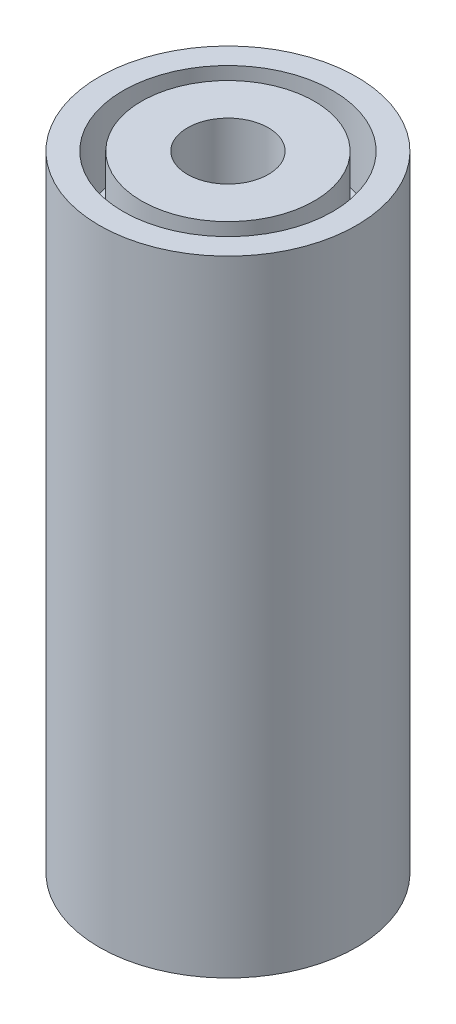
from build123d import *

# Parameters (mm, degrees)
ESQUISSE1_R             = 3.5
ESQUISSE1_R_2           = 1.1
BOSS_EXTRU_2_DEPTH      = 17
ESQUISSE2_R             = 2.85
ESQUISSE2_R_2           = 2.35
ENL_V_MAT_EXTRU_1_DEPTH = 2


with BuildPart() as part:
    # Esquisse1 → Boss.-Extru.2 (new body)
    with BuildSketch(Plane(origin=(0, 0, 0), x_dir=(1, 0, 0), z_dir=(0, 1, 0))):
        Circle(ESQUISSE1_R)
        Circle(ESQUISSE1_R_2, mode=Mode.SUBTRACT)
    extrude(amount=BOSS_EXTRU_2_DEPTH)

    # Esquisse2 → Enlèv. mat.-Extru.1 (cut)
    with BuildSketch(Plane(origin=(0, 17, 0), x_dir=(1, 0, 0), z_dir=(0, 1, 0))):
        Circle(ESQUISSE2_R)
        Circle(ESQUISSE2_R_2, mode=Mode.SUBTRACT)
    extrude(amount=-ENL_V_MAT_EXTRU_1_DEPTH, mode=Mode.SUBTRACT)


solid = part.part
